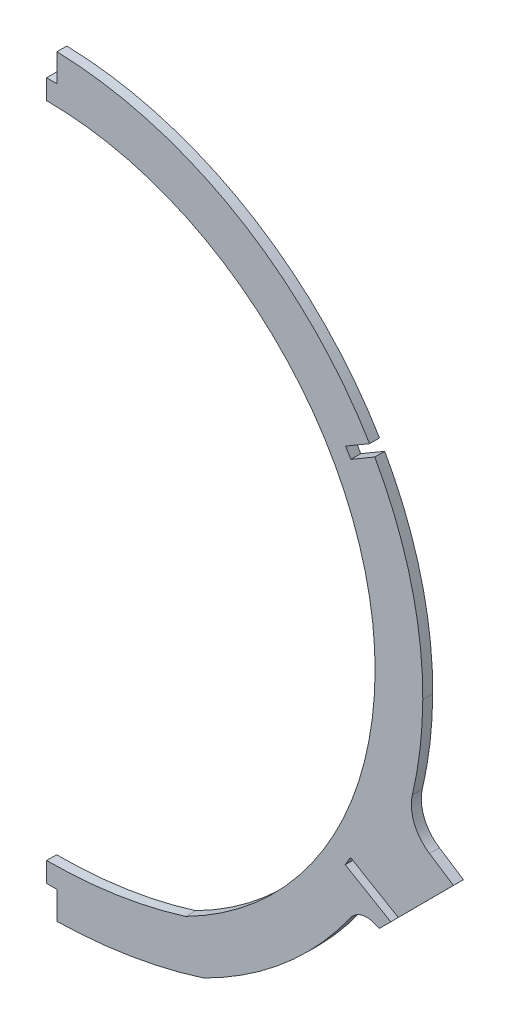
from build123d import *

# Parameters (mm, degrees)
BOSS_EXTRUDE1_DEPTH = 1.5875
SKETCH3_W           = 208.645691316
SKETCH3_H           = 383.026987577
CUT_EXTRUDE1_DEPTH  = 121.098895727
BOSS_EXTRUDE2_DEPTH = 1.5875
FILLET1_R           = 6.35
FILLET2_R           = 12.7
SKETCH6_W           = 3.302
SKETCH6_H           = 12.7
CUT_EXTRUDE2_DEPTH  = 4.175


with BuildPart() as part:
    # Sketch2 → Boss-Extrude1 (new body, symmetric)
    with BuildSketch(Plane.XY):
        with BuildLine():
            ThreePointArc((-120.098895727, 19.05), (0.406748907, 139.2017743), (120.203613722, 18.343301545))
            ThreePointArc((120.203613722, 18.343301545), (101.067699546, -47.629728931), (50.138751442, -93.726))
            ThreePointArc((50.138751442, -93.726), (0.040174098, -101.514794876), (-50.058403246, -93.726))
            ThreePointArc((-50.058403246, -93.726), (-101.163912713, -47.327889321), (-120.098895727, 19.05))
        make_face()
        with BuildLine():
            ThreePointArc((-104.858895727, 19.05), (0.361930242, 123.961840203), (104.963877332, 18.432938489))
            ThreePointArc((104.963877332, 18.432938489), (88.446745877, -39.065849025), (44.40486057, -79.553359885))
            ThreePointArc((44.40486057, -79.553359885), (0.040463589, -86.274794876), (-44.323959374, -79.553531384))
            ThreePointArc((-44.323959374, -79.553531384), (-88.517658334, -38.801393502), (-104.858895727, 19.05))
        make_face(mode=Mode.SUBTRACT)
    extrude(amount=BOSS_EXTRUDE1_DEPTH, both=True)

    # Sketch3 → Cut-Extrude1 (cut, through all)
    with BuildSketch(Plane(origin=(0, 0, 0), x_dir=(0, 0, -1), z_dir=(1, 0, 0))):
        with Locations((4.266053154, 20.866300598)):
            Rectangle(SKETCH3_W, SKETCH3_H)
    extrude(amount=-CUT_EXTRUDE1_DEPTH, mode=Mode.SUBTRACT)

    # Sketch5 → Boss-Extrude2 (add, symmetric)
    with BuildSketch(Plane.XY):
        Polygon((106.258152496, -51.988683319), (130.011728615, -28.168431361), (114.573822099, -18.142937646), (100.046993583, -49.235229101), align=None)
    extrude(amount=BOSS_EXTRUDE2_DEPTH, both=True)

    # Fillet1
    fillet1_edges = [part.edges().sort_by_distance(p)[0] for p in [
        (100.046993583, -49.235229101, 0),
    ]]
    fillet(fillet1_edges, radius=FILLET1_R)

    # Fillet2
    fillet2_edges = [part.edges().sort_by_distance(p)[0] for p in [
        (114.573822099, -18.142937646, 0),
    ]]
    fillet(fillet2_edges, radius=FILLET2_R)

    # Sketch6 → Cut-Extrude2 (cut, through all)
    with BuildSketch(Plane.XY.offset(1.5875)):
        with Locations((1.651, 136.662280289)):
            Rectangle(SKETCH6_W, SKETCH6_H)
        Polygon((108.166218002, 79.740204673), (106.494925174, 82.588008087), (95.541835122, 76.159958748), (97.21312795, 73.312155334), align=None)
        Polygon((95.424252626, -39.741107061), (97.095545407, -36.89330362), (118.130209204, -49.237934313), (116.458916422, -52.085737754), align=None)
        with Locations((1.651, -98.974789488)):
            Rectangle(SKETCH6_W, SKETCH6_H)
    extrude(amount=-CUT_EXTRUDE2_DEPTH, mode=Mode.SUBTRACT)


solid = part.part
